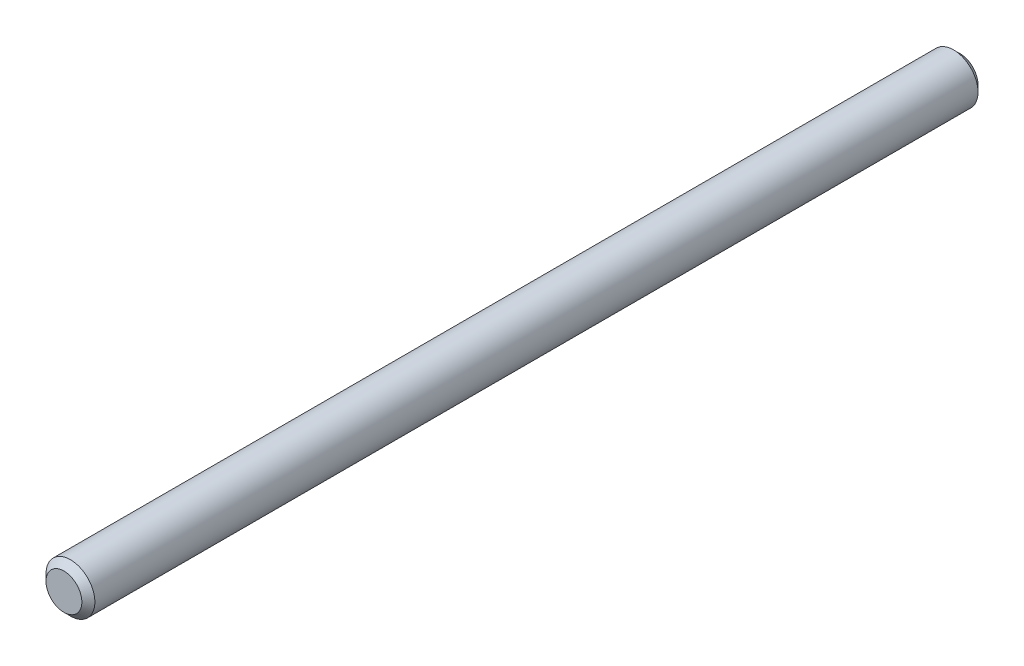
from build123d import *

# Parameters (mm, degrees)
SKETCH1_R           = 7.5
BOSS_EXTRUDE1_DEPTH = 137.5
CHAMFER1_SIZE       = 2


with BuildPart() as part:
    # Sketch1 → Boss-Extrude1 (new body, symmetric)
    with BuildSketch(Plane.XY):
        Circle(SKETCH1_R)
    extrude(amount=BOSS_EXTRUDE1_DEPTH, both=True)

    # Chamfer1
    chamfer1_edges = [part.edges().sort_by_distance(p)[0] for p in [
        (-7.5, 0, -137.5),
        (-7.5, 0, 137.5),
    ]]
    chamfer(chamfer1_edges, length=CHAMFER1_SIZE)


solid = part.part
